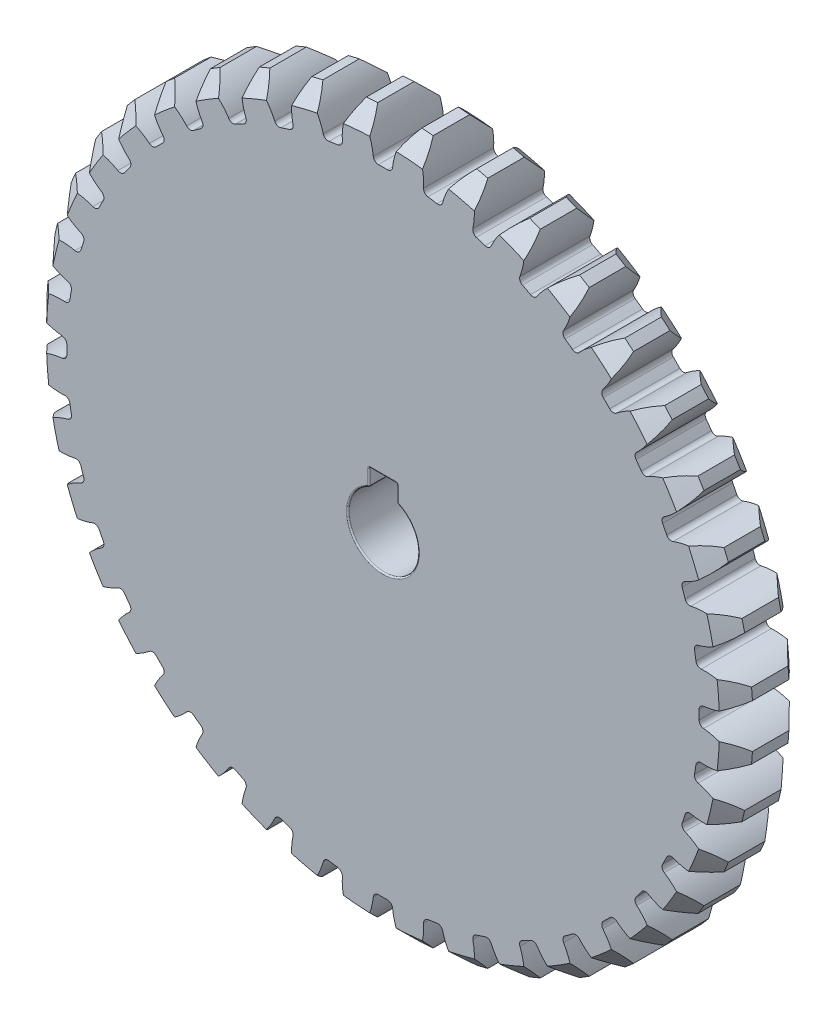
from build123d import *

# Parameters (mm, degrees)
SKETCH1_R                = 50.4
BOSS_EXTRUDE1_DEPTH      = 5
CUT_EXTRUDE1_DEPTH       = 6
FILLET1_R                = 0.72
CHAMFER1_SIZE            = 2.4
CIRPATTERN1_COUNT        = 40
FILLET1_OF_CIRPATTERN1_R = 0.72
CUT_EXTRUDE2_DEPTH       = 11.0000001
FILLET2_R                = 0.2


with BuildPart() as part:
    # Sketch1 → Boss-Extrude1 (new body, symmetric)
    with BuildSketch(Plane.XY):
        Circle(SKETCH1_R)
    extrude(amount=BOSS_EXTRUDE1_DEPTH, both=True)

    # Sketch2 → Cut-Extrude1 (cut, symmetric)
    with BuildSketch(Plane.XY):
        with BuildLine():
            ThreePointArc((3.142611173, 50.301928343), (1.837175063, 47.829886602), (1.332156339, 45.0803212))
            ThreePointArc((1.332156339, 45.0803212), (0, 45.1), (-1.332156339, 45.0803212))
            ThreePointArc((-1.332156339, 45.0803212), (-1.837175063, 47.829886602), (-3.142611173, 50.301928343))
            ThreePointArc((-3.142611173, 50.301928343), (0, 50.4), (3.142611173, 50.301928343))
        make_face()
    cut_extrude1 = extrude(amount=CUT_EXTRUDE1_DEPTH, both=True, mode=Mode.SUBTRACT)

    # Fillet1
    fillet1_edges = [part.edges().sort_by_distance(p)[0] for p in [
        (1.332156339, 45.0803212, 0),
        (-1.332156339, 45.0803212, 0),
    ]]
    fillet(fillet1_edges, radius=FILLET1_R)

    # Chamfer1
    chamfer1_edges = [part.edges().sort_by_distance(p)[0] for p in [
        (-34.509219035, -36.732462503, -5),
        (-34.509219035, -36.732462503, 5),
    ]]
    chamfer(chamfer1_edges, length=CHAMFER1_SIZE)

    # CirPattern1: Cut-Extrude1 ×40 about axis
    cirpattern1_axis = Axis((0, 0, 0), (0, 0, 1))
    for i in range(1, CIRPATTERN1_COUNT):
        add(cut_extrude1.rotate(cirpattern1_axis, i * 360 / CIRPATTERN1_COUNT), mode=Mode.SUBTRACT)

    # Fillet1 of CirPattern1
    fillet1_of_cirpattern1_edges = [part.edges().sort_by_distance(p)[0] for p in [
        (-5.736360647, 44.733702804, 0),
        (-8.367871215, 44.316912475, 0),
        (-12.663629395, 43.285592182, 0),
        (-15.19754133, 42.462274286, 0),
        (-19.27907756, 40.771646624, 0),
        (-21.65299754, 39.562073979, 0),
        (-25.419810852, 37.253767813, 0),
        (-27.575285088, 35.687724113, 0),
        (-30.934624037, 32.8185776, 0),
        (-32.8185776, 30.934624037, 0),
        (-35.687724113, 27.575285088, 0),
        (-37.253767813, 25.419810852, 0),
        (-39.562073979, 21.65299754, 0),
        (-40.771646624, 19.27907756, 0),
        (-42.462274286, 15.19754133, 0),
        (-43.285592182, 12.663629395, 0),
        (-44.316912475, 8.367871215, 0),
        (-44.733702804, 5.736360647, 0),
        (-45.0803212, 1.332156339, 0),
        (-45.0803212, -1.332156339, 0),
        (-44.733702804, -5.736360647, 0),
        (-44.316912475, -8.367871215, 0),
        (-43.285592182, -12.663629395, 0),
        (-42.462274286, -15.19754133, 0),
        (-40.771646624, -19.27907756, 0),
        (-39.562073979, -21.65299754, 0),
        (-37.253767813, -25.419810852, 0),
        (-35.687724113, -27.575285088, 0),
        (-32.8185776, -30.934624037, 0),
        (-30.934624037, -32.8185776, 0),
        (-27.575285088, -35.687724113, 0),
        (-25.419810852, -37.253767813, 0),
        (-21.65299754, -39.562073979, 0),
        (-19.27907756, -40.771646624, 0),
        (-15.19754133, -42.462274286, 0),
        (-12.663629395, -43.285592182, 0),
        (-8.367871215, -44.316912475, 0),
        (-5.736360647, -44.733702804, 0),
        (-1.332156339, -45.0803212, 0),
        (1.332156339, -45.0803212, 0),
        (5.736360647, -44.733702804, 0),
        (8.367871215, -44.316912475, 0),
        (12.663629395, -43.285592182, 0),
        (15.19754133, -42.462274286, 0),
        (19.27907756, -40.771646624, 0),
        (21.65299754, -39.562073979, 0),
        (25.419810852, -37.253767813, 0),
        (27.575285088, -35.687724113, 0),
        (30.934624037, -32.8185776, 0),
        (32.8185776, -30.934624037, 0),
        (35.687724113, -27.575285088, 0),
        (37.253767813, -25.419810852, 0),
        (39.562073979, -21.65299754, 0),
        (40.771646624, -19.27907756, 0),
        (42.462274286, -15.19754133, 0),
        (43.285592182, -12.663629395, 0),
        (44.316912475, -8.367871215, 0),
        (44.733702804, -5.736360647, 0),
        (45.0803212, -1.332156339, 0),
        (45.0803212, 1.332156339, 0),
        (44.733702804, 5.736360647, 0),
        (44.316912475, 8.367871215, 0),
        (43.285592182, 12.663629395, 0),
        (42.462274286, 15.19754133, 0),
        (40.771646624, 19.27907756, 0),
        (39.562073979, 21.65299754, 0),
        (37.253767813, 25.419810852, 0),
        (35.687724113, 27.575285088, 0),
        (32.8185776, 30.934624037, 0),
        (30.934624037, 32.8185776, 0),
        (27.575285088, 35.687724113, 0),
        (25.419810852, 37.253767813, 0),
        (21.65299754, 39.562073979, 0),
        (19.27907756, 40.771646624, 0),
        (15.19754133, 42.462274286, 0),
        (12.663629395, 43.285592182, 0),
        (8.367871215, 44.316912475, 0),
        (5.736360647, 44.733702804, 0),
    ]]
    fillet(fillet1_of_cirpattern1_edges, radius=FILLET1_OF_CIRPATTERN1_R)

    # Sketch3 → Cut-Extrude2 (cut, through all)
    with BuildSketch(Plane.XY.offset(5)):
        with BuildLine():
            Line((-2, 4.582575695), (-2, 7))
            Line((-2, 7), (2, 7))
            Line((2, 7), (2, 4.582575695))
            ThreePointArc((2, 4.582575695), (0, -5), (-2, 4.582575695))
        make_face()
    extrude(amount=-CUT_EXTRUDE2_DEPTH, mode=Mode.SUBTRACT)

    # Fillet2
    fillet2_edges = [part.edges().sort_by_distance(p)[0] for p in [
        (0, -5, -5),
        (2, 4.582575695, 0),
        (-2, 5.791287847, -5),
        (-2, 4.582575695, 0),
        (0, 7, -5),
        (-2, 7, 0),
        (2, 5.791287847, -5),
        (2, 7, 0),
        (0, -5, 5),
        (2, 5.791287847, 5),
        (0, 7, 5),
        (-2, 5.791287847, 5),
    ]]
    fillet(fillet2_edges, radius=FILLET2_R)


solid = part.part
